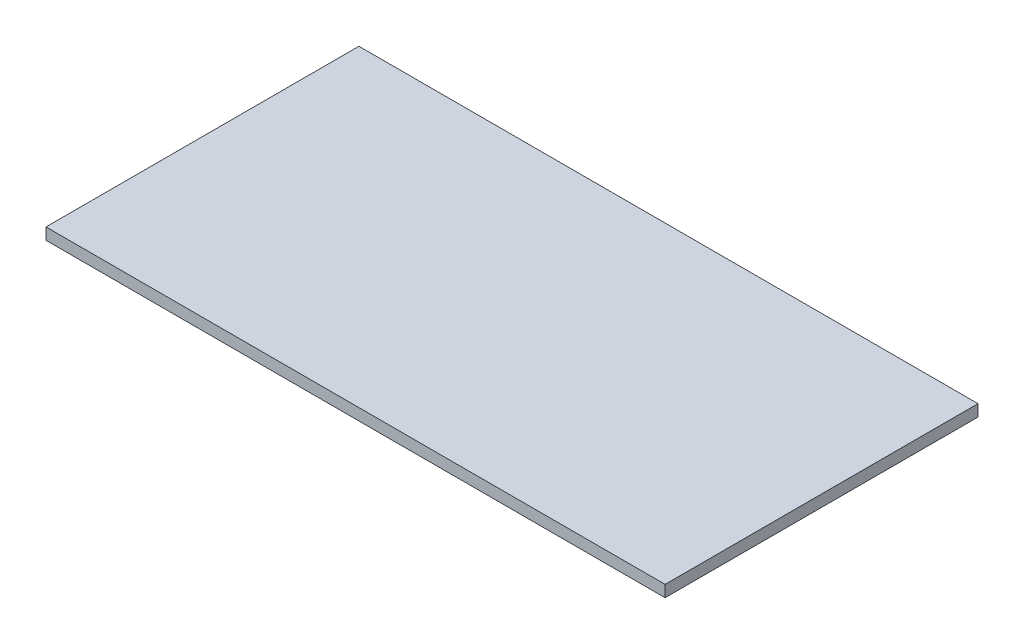
from build123d import *

# Parameters (mm, degrees)
SKETCH1_W           = 162.56
SKETCH1_H           = 82.169
BOSS_EXTRUDE1_DEPTH = 3.048


with BuildPart() as part:
    # Sketch1 → Boss-Extrude1 (new body)
    with BuildSketch(Plane(origin=(0, 0, 0), x_dir=(1, 0, 0), z_dir=(0, 1, 0))):
        with Locations((-81.28, 41.0845)):
            Rectangle(SKETCH1_W, SKETCH1_H)
    extrude(amount=BOSS_EXTRUDE1_DEPTH)


solid = part.part
